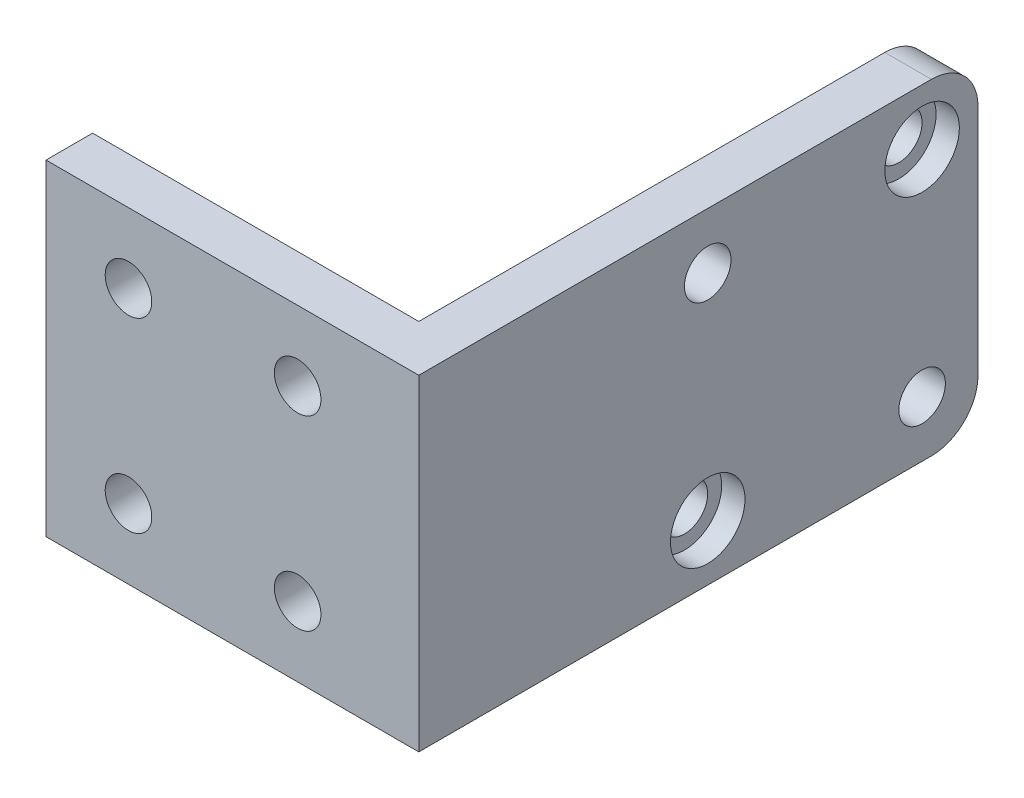
from build123d import *

# Parameters (mm, degrees)
BOSS_EXTRUDE1_DEPTH = 35
FILLET1_R           = 5
SKETCH2_R           = 2.5
CUT_EXTRUDE1_DEPTH  = 6
SKETCH3_R           = 2.5
CUT_EXTRUDE3_DEPTH  = 6
SKETCH5_R           = 4
CUT_EXTRUDE5_DEPTH  = 2.5


with BuildPart() as part:
    # Sketch1 → Boss-Extrude1 (new body)
    with BuildSketch(Plane(origin=(0, 0, 0), x_dir=(1, 0, 0), z_dir=(0, 1, 0))):
        Polygon((0, 0), (0, 5), (35, 5), (35, 60), (40, 60), (40, 0), align=None)
    extrude(amount=BOSS_EXTRUDE1_DEPTH)

    # Fillet1
    fillet1_edges = [part.edges().sort_by_distance(p)[0] for p in [
        (37.5, 35, -60),
        (37.5, 0, -60),
    ]]
    fillet(fillet1_edges, radius=FILLET1_R)

    # Sketch2 → Cut-Extrude1 (cut, through all)
    with BuildSketch(Plane(origin=(0, 0, -5), x_dir=(-1, 0, 0), z_dir=(0, 0, -1))):
        with Locations((-27.000416448, 27.5)):
            Circle(SKETCH2_R)
        with Locations((-8.85118862, 27.5)):
            Circle(SKETCH2_R)
        with Locations((-27.000416448, 7.5)):
            Circle(SKETCH2_R)
        with Locations((-8.85118862, 7.5)):
            Circle(SKETCH2_R)
    extrude(amount=-CUT_EXTRUDE1_DEPTH, mode=Mode.SUBTRACT)

    # Sketch3 → Cut-Extrude3 (cut, through all)
    with BuildSketch(Plane.ZY.offset(-35)):
        with Locations((-31, 29)):
            Circle(SKETCH3_R)
        with Locations((-54, 6)):
            Circle(SKETCH3_R)
        with Locations((-54, 29)):
            Circle(SKETCH3_R)
        with Locations((-31, 6)):
            Circle(SKETCH3_R)
    extrude(amount=-CUT_EXTRUDE3_DEPTH, mode=Mode.SUBTRACT)

    # Sketch5 → Cut-Extrude5 (cut)
    with BuildSketch(Plane(origin=(40, 0, 0), x_dir=(0, 0, -1), z_dir=(1, 0, 0))):
        with Locations((54, 29)):
            Circle(SKETCH5_R)
        with Locations((31, 6)):
            Circle(SKETCH5_R)
    extrude(amount=-CUT_EXTRUDE5_DEPTH, mode=Mode.SUBTRACT)


solid = part.part
